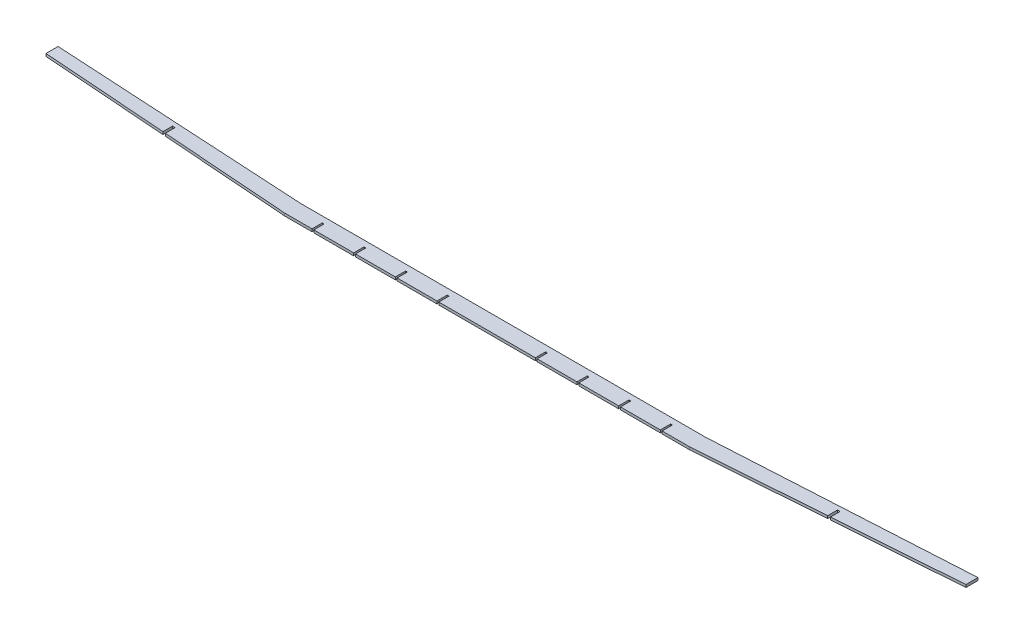
from build123d import *

# Parameters (mm, degrees)
BOSS_EXTRUDE1_DEPTH = 4.3
CUT_EXTRUDE1_START  = -5.3
SKETCH2_W           = 3
SKETCH2_H           = 17
SKETCH2_W_2         = 4.3
SKETCH2_H_2         = 16.2
CUT_EXTRUDE1_DEPTH  = 6.3


with BuildPart() as part:
    # Sketch1 → Boss-Extrude1 (new body)
    with BuildSketch(Plane(origin=(0, 0, 0), x_dir=(1, 0, 0), z_dir=(0, 1, 0))):
        Polygon((335.3, -13.5), (762, 17.8), (762, 37.8), (335.3, 13.5), (0, 13.5), (0, -13.5), align=None)
    boss_extrude1 = extrude(amount=BOSS_EXTRUDE1_DEPTH)

    # Sketch2 → Cut-Extrude1 (cut)
    with BuildSketch(Plane(origin=(0, 4.3, 0), x_dir=(1, 0, 0), z_dir=(0, 1, 0)).offset(CUT_EXTRUDE1_START)):
        with Locations((81.5, -5)):
            Rectangle(SKETCH2_W, SKETCH2_H)
        with Locations((150.5, -5)):
            Rectangle(SKETCH2_W, SKETCH2_H)
        with Locations((219.5, -5)):
            Rectangle(SKETCH2_W, SKETCH2_H)
        with Locations((288.5, -5)):
            Rectangle(SKETCH2_W, SKETCH2_H)
        with Locations((550.81, 10.250733536)):
            Rectangle(SKETCH2_W_2, SKETCH2_H_2)
    cut_extrude1 = extrude(amount=CUT_EXTRUDE1_DEPTH, mode=Mode.SUBTRACT)

    # Mirror1: Boss-Extrude1, Cut-Extrude1 across plane
    add(boss_extrude1.mirror(Plane(origin=(0, 0, 0), x_dir=(0, 0, 1), z_dir=(1, 0, 0))))
    add(cut_extrude1.mirror(Plane(origin=(0, 0, 0), x_dir=(0, 0, 1), z_dir=(1, 0, 0))), mode=Mode.SUBTRACT)


solid = part.part
